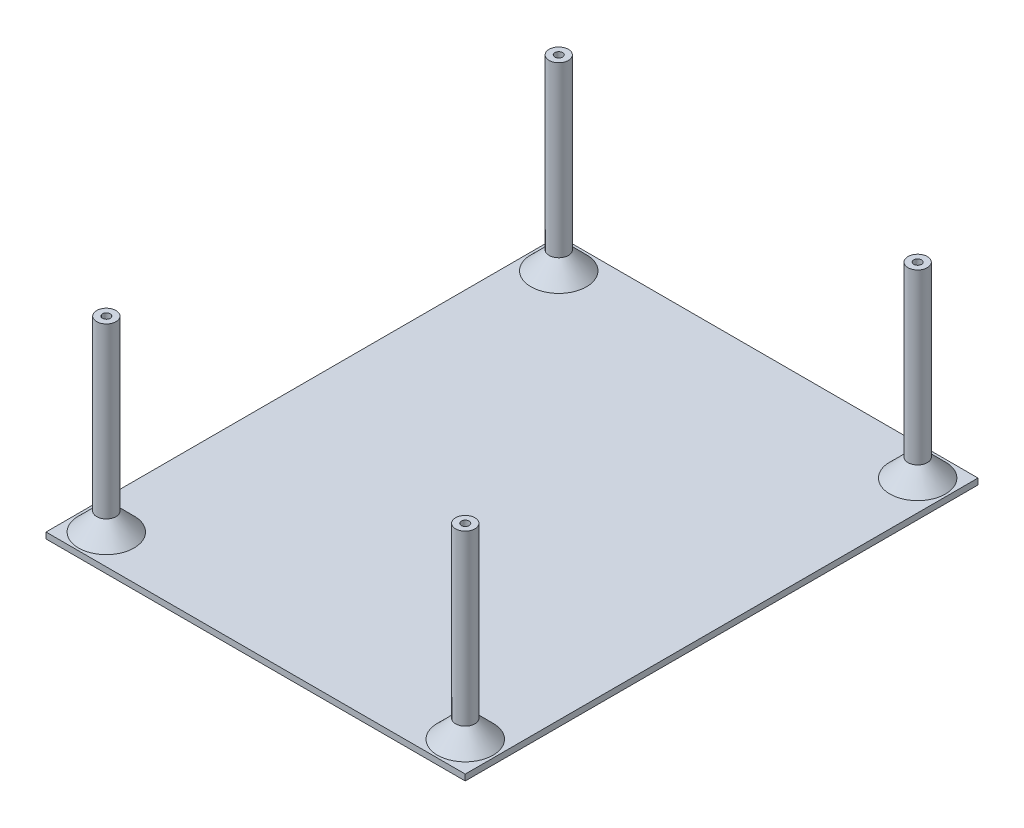
from build123d import *

# Parameters (mm, degrees)
SKETCH_1_W          = 69.5
SKETCH_1_H          = 85
EXTRUDE_1_DEPTH     = 1
SKETCH_2_R          = 1.6
EXTRUDE_2_DEPTH     = 31
SKETCH_3_R          = 0.65
CUT_EXTRUDE_1_DEPTH = 5
CHAMFER_1_SIZE      = 3


with BuildPart() as part:
    # Эскиз1 → Бобышка-Вытянуть1 (new body)
    with BuildSketch(Plane(origin=(0, 0, 0), x_dir=(1, 0, 0), z_dir=(0, 1, 0))):
        with Locations((6.099344978, -9.693231441)):
            Rectangle(SKETCH_1_W, SKETCH_1_H)
    extrude(amount=EXTRUDE_1_DEPTH)

    # Эскиз2 → Бобышка-Вытянуть2 (add)
    with BuildSketch(Plane(origin=(0, 1, 0), x_dir=(1, 0, 0), z_dir=(0, 1, 0))):
        with Locations((-23.650655022, 27.806768559)):
            Circle(SKETCH_2_R)
        with Locations((35.849344978, 27.806768559)):
            Circle(SKETCH_2_R)
        with Locations((35.849344978, -47.193231441)):
            Circle(SKETCH_2_R)
        with Locations((-23.650655022, -47.193231441)):
            Circle(SKETCH_2_R)
    extrude(amount=EXTRUDE_2_DEPTH)

    # Эскиз3 → Вырез-Вытянуть1 (cut)
    with BuildSketch(Plane(origin=(0, 32, 0), x_dir=(1, 0, 0), z_dir=(0, 1, 0))):
        with Locations((-23.650655022, -47.193231441)):
            Circle(SKETCH_3_R)
        with Locations((35.849344978, -47.193231441)):
            Circle(SKETCH_3_R)
        with Locations((35.849344978, 27.806768559)):
            Circle(SKETCH_3_R)
        with Locations((-23.650655022, 27.806768559)):
            Circle(SKETCH_3_R)
    extrude(amount=-CUT_EXTRUDE_1_DEPTH, mode=Mode.SUBTRACT)

    # Фаска1
    chamfer_1_edges = [part.edges().sort_by_distance(p)[0] for p in [
        (-25.250655022, 1, -27.806768559),
        (34.249344978, 1, -27.806768559),
        (34.249344978, 1, 47.193231441),
        (-25.250655022, 1, 47.193231441),
    ]]
    chamfer(chamfer_1_edges, length=CHAMFER_1_SIZE)


solid = part.part
